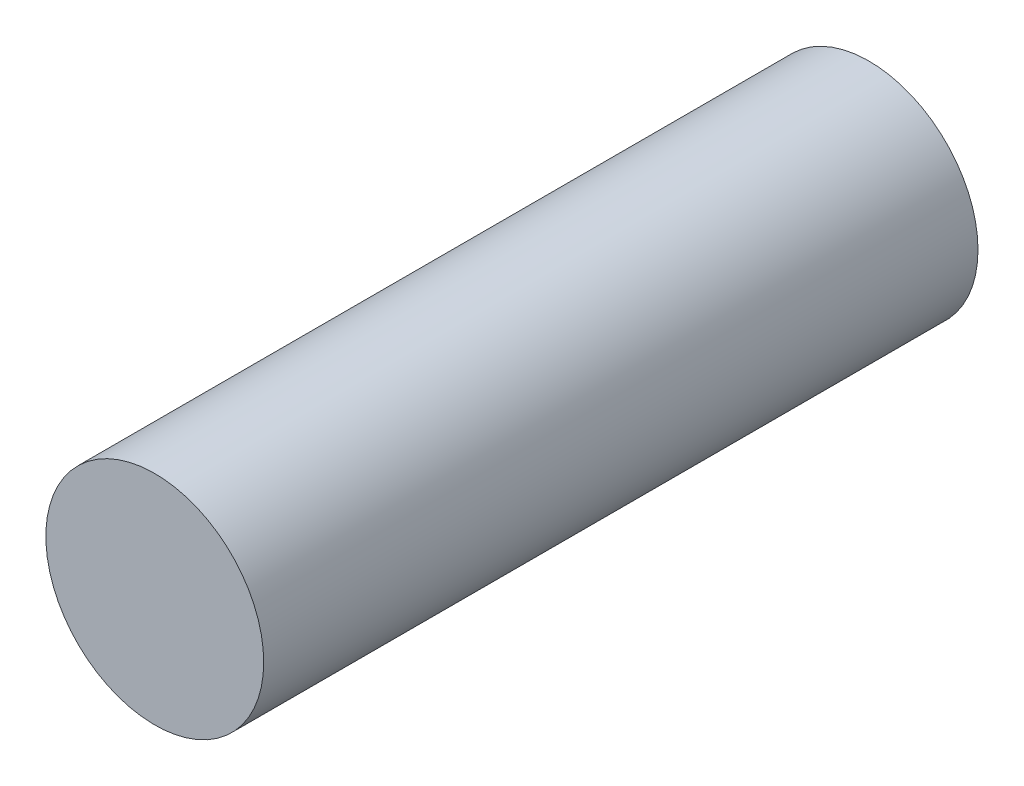
from build123d import *

# Parameters (mm, degrees)
SKETCH1_R                = 3.05
BOSS_EXTRUDE1_DEPTH      = 3
BOSS_EXTRUDE1_DEPTH_BACK = 17


with BuildPart() as part:
    # Sketch1 → Boss-Extrude1 (new body, two sides)
    with BuildSketch(Plane.XY) as boss_extrude1_sk:
        Circle(SKETCH1_R)
    extrude(amount=BOSS_EXTRUDE1_DEPTH)
    extrude(boss_extrude1_sk.sketch, amount=-BOSS_EXTRUDE1_DEPTH_BACK)


solid = part.part
